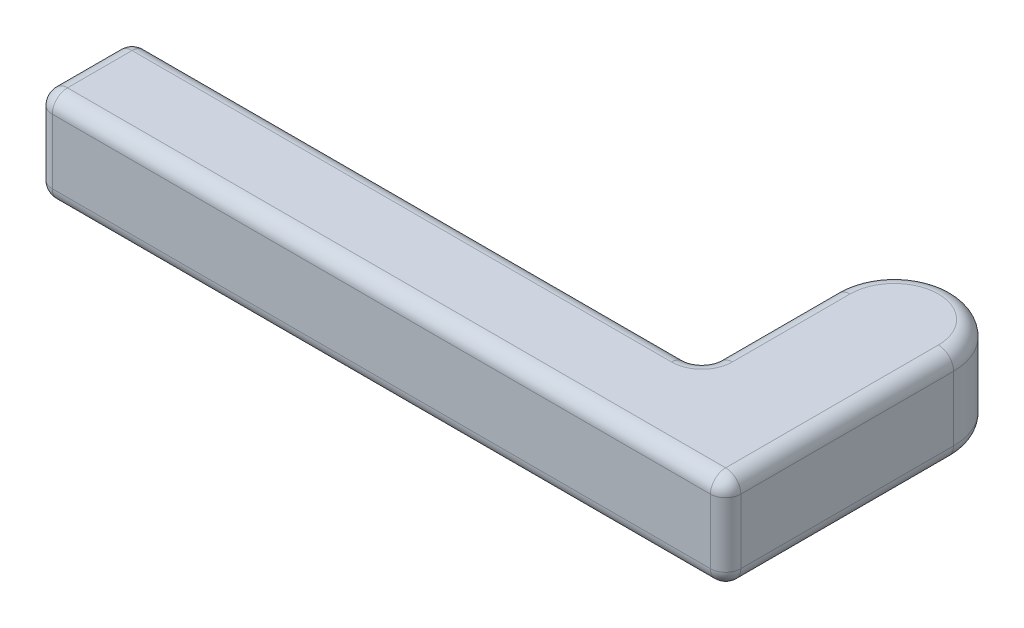
from build123d import *

# Parameters (mm, degrees)
BOSS_EXTRUDE2_DEPTH = 12.7
FILLET1_R           = 2.032


with BuildPart() as part:
    # Sketch1 → Boss-Extrude2 (new body)
    with BuildSketch(Plane(origin=(0, 0, 0), x_dir=(1, 0, 0), z_dir=(0, 1, 0))):
        with BuildLine():
            Line((-13.367399368, 0), (78.707600632, 0))
            Line((78.707600632, 0), (78.707600632, 30.48))
            ThreePointArc((78.707600632, 30.48), (70.770100632, 38.4175), (62.832600632, 30.48))
            Line((62.832600632, 30.48), (62.832600632, 12.7))
            Line((62.832600632, 12.7), (-13.367399368, 12.7))
            Line((-13.367399368, 12.7), (-13.367399368, 0))
        make_face()
    extrude(amount=BOSS_EXTRUDE2_DEPTH)

    # Fillet1
    fillet1_edges = [part.edges().sort_by_distance(p)[0] for p in [
        (-13.367399368, 6.35, -12.7),
        (62.832600632, 6.35, -12.7),
        (78.707600632, 6.35, 0),
        (-13.367399368, 6.35, 0),
        (78.707600632, 12.7, -15.24),
        (70.770100632, 12.7, -38.4175),
        (62.832600632, 12.7, -21.59),
        (24.732600632, 12.7, -12.7),
        (-13.367399368, 12.7, -6.35),
        (24.732600632, 0, -12.7),
        (62.832600632, 0, -21.59),
        (70.770100632, 0, -38.4175),
        (78.707600632, 0, -15.24),
        (32.670100632, 0, 0),
        (-13.367399368, 0, -6.35),
        (32.670100632, 12.7, 0),
    ]]
    fillet(fillet1_edges, radius=FILLET1_R)


solid = part.part
